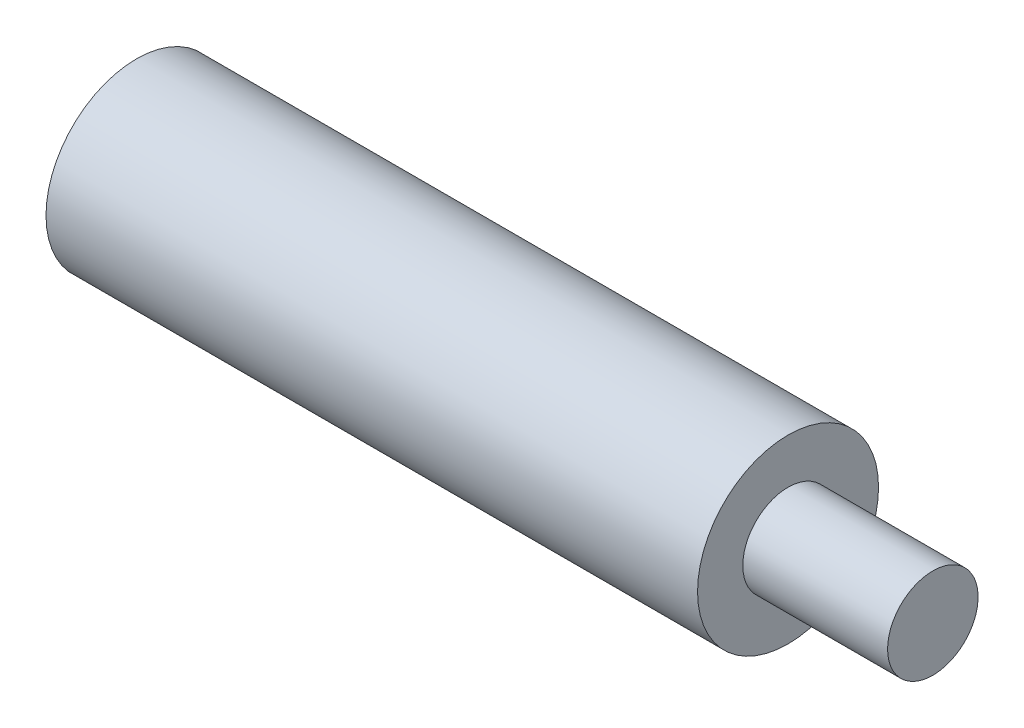
from build123d import *

# Parameters (mm, degrees)
M5_GEWINDEBOHRUNG1_D     = 4.2
M5_GEWINDEBOHRUNG1_DEPTH = 14
M5_GEWINDEBOHRUNG1_TIP   = 1.2618073


with BuildPart() as part:
    # Skizze1 → Rotation1 (revolve)
    with BuildSketch(Plane.XY):
        Polygon((0, 0), (0, 5), (36, 5), (36, 2.5), (44, 2.5), (44, 0), align=None)
    revolve(axis=Axis((0, 0, 0), (1, 0, 0)))

    # M5 Gewindebohrung1
    with Locations(Plane.ZY):
        with Locations((0, 0)):
            Hole(M5_GEWINDEBOHRUNG1_D / 2, depth=M5_GEWINDEBOHRUNG1_DEPTH)
            with Locations((0, 0, -(M5_GEWINDEBOHRUNG1_DEPTH + M5_GEWINDEBOHRUNG1_TIP / 2))):  # 118° drill point
                Cone(0, M5_GEWINDEBOHRUNG1_D / 2, M5_GEWINDEBOHRUNG1_TIP, mode=Mode.SUBTRACT)


solid = part.part
